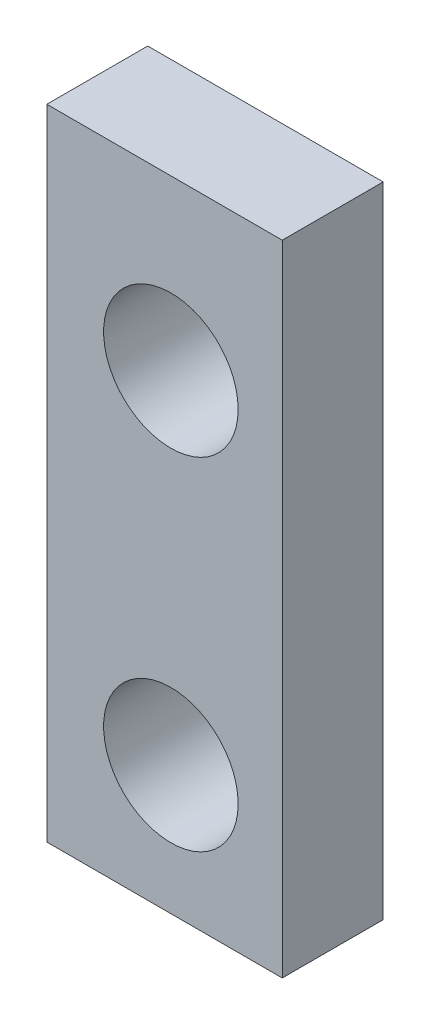
from build123d import *

# Parameters (mm, degrees)
SKETCH2_W           = 7
SKETCH2_H           = 19
SKETCH2_R           = 2
BOSS_EXTRUDE1_DEPTH = 3


with BuildPart() as part:
    # Sketch2 → Boss-Extrude1 (new body)
    with BuildSketch(Plane.XY):
        with Locations((-16.5, 16.62)):
            Rectangle(SKETCH2_W, SKETCH2_H)
        with Locations((-16.312, 21.106)):
            Circle(SKETCH2_R, mode=Mode.SUBTRACT)
        with Locations((-16.312, 10.946)):
            Circle(SKETCH2_R, mode=Mode.SUBTRACT)
    extrude(amount=BOSS_EXTRUDE1_DEPTH)


solid = part.part
